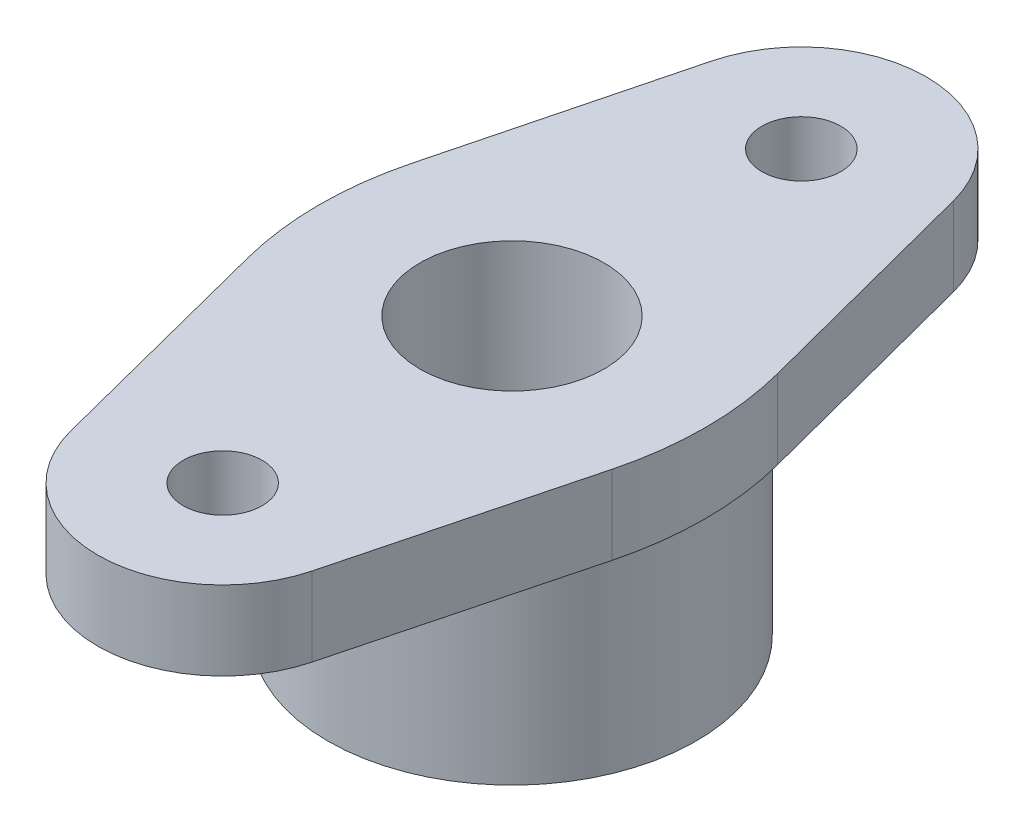
from build123d import *

# Parameters (mm, degrees)
SKETCH1_R           = 14
SKETCH1_R_2         = 19
SKETCH1_R_3         = 6
BOSS_EXTRUDE1_DEPTH = 12
FILLET1_R           = 50


with BuildPart() as part:
    # Sketch1 → Boss-Extrude1 (new body)
    with BuildSketch(Plane(origin=(0, 0, 0), x_dir=(1, 0, 0), z_dir=(0, 1, 0))):
        with BuildLine():
            Line((31.065401992, 0), (18.389205605, 48.778819646))
            ThreePointArc((18.389205605, 48.778819646), (18.846682818, 46.408847598), (19, 44))
            ThreePointArc((19, 44), (-2.385148225, 25.15030324), (-18.401165047, 48.732560082))
            Line((-18.401165047, 48.732560082), (-30.934598008, 0))
            Line((-30.934598008, 0), (-18.401165047, -48.732560082))
            ThreePointArc((-18.401165047, -48.732560082), (-2.385148225, -25.15030324), (19, -44))
            ThreePointArc((19, -44), (18.846682818, -46.408847598), (18.389205605, -48.778819646))
            Line((18.389205605, -48.778819646), (31.065401992, 0))
        make_face()
        Circle(SKETCH1_R, mode=Mode.SUBTRACT)
        with Locations((0, -44)):
            Circle(SKETCH1_R_2)
        with Locations((0, -44)):
            Circle(SKETCH1_R_3, mode=Mode.SUBTRACT)
        with Locations((0, 44)):
            Circle(SKETCH1_R_2)
        with Locations((0, 44)):
            Circle(SKETCH1_R_3, mode=Mode.SUBTRACT)
    extrude(amount=BOSS_EXTRUDE1_DEPTH)

    # Fillet1
    fillet1_edges = [part.edges().sort_by_distance(p)[0] for p in [
        (-30.934598008, 6, 0),
        (31.065401992, 6, 0),
    ]]
    fillet(fillet1_edges, radius=FILLET1_R)

    # Sketch3 → Revolve1 (revolve)
    with BuildSketch(Plane.XY):
        Polygon((14, 0), (28, 0), (28, -30), (14, -21.917096231), align=None)
    revolve(axis=Axis((0, 0, 0), (0, -1, 0)))


solid = part.part
